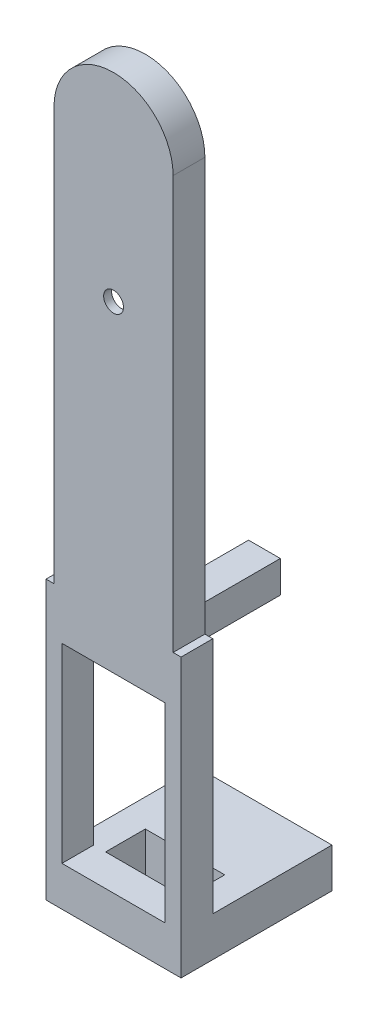
from build123d import *

# Parameters (mm, degrees)
EXTRUDE_1_DEPTH     = 4
CUT_EXTRUDE_1_DEPTH = 3
SKETCH_5_R          = 1.25
CUT_EXTRUDE_2_DEPTH = 12.4
SKETCH_6_W          = 17
SKETCH_6_H          = 35
EXTRUDE_2_DEPTH     = 4
SKETCH_7_W          = 13
SKETCH_7_H          = 24
CUT_EXTRUDE_3_DEPTH = 12.1
SKETCH_8_W          = 4
SKETCH_8_H          = 4
SKETCH_8_R          = 1.175
EXTRUDE_3_DEPTH     = 15
EXTRUDE_4_DEPTH     = 5
SKETCH_10_R         = 1.175
CUT_EXTRUDE_4_DEPTH = 12.7


with BuildPart() as part:
    # 草圖1 → 填料-伸長1 (new body)
    with BuildSketch(Plane.XY):
        with BuildLine():
            Line((7.5, 0), (7.5, 52))
            ThreePointArc((7.5, 52), (0, 59.5), (-7.5, 52))
            Line((-7.5, 52), (-7.5, 0))
            Line((-7.5, 0), (7.5, 0))
        make_face()
    extrude(amount=EXTRUDE_1_DEPTH)

    # 草圖3 → 除料-伸長1 (cut)
    with BuildSketch(Plane.XY):
        with BuildLine():
            ThreePointArc((-2.132795501, 52), (0, 54.132795501), (2.132795501, 52))
            Line((2.132795501, 52), (5, 34.5))
            Line((5, 34.5), (2.114741289, 16.658021353))
            ThreePointArc((2.114741289, 16.658021353), (-0.171540182, 14.864665347), (-2.142213835, 17))
            Line((-2.142213835, 17), (-5, 34.5))
            Line((-5, 34.5), (-2.132795501, 52))
        make_face()
    extrude(amount=CUT_EXTRUDE_1_DEPTH, mode=Mode.SUBTRACT)

    # 草圖5 → 除料-伸長2 (cut)
    with BuildSketch(Plane.XY):
        with Locations((0, 34.5)):
            Circle(SKETCH_5_R)
    extrude(amount=CUT_EXTRUDE_2_DEPTH, mode=Mode.SUBTRACT)

    # 草圖6 → 填料-伸長2 (add)
    with BuildSketch(Plane.XY):
        with Locations((0, -17.5)):
            Rectangle(SKETCH_6_W, SKETCH_6_H)
    extrude(amount=EXTRUDE_2_DEPTH)

    # 草圖7 → 除料-伸長3 (cut)
    with BuildSketch(Plane.XY):
        with Locations((0, -18)):
            Rectangle(SKETCH_7_W, SKETCH_7_H)
    extrude(amount=CUT_EXTRUDE_3_DEPTH, mode=Mode.SUBTRACT)

    # 草圖8 → 填料-伸長3 (add)
    with BuildSketch(Plane.XY):
        with Locations((0, -4)):
            Rectangle(SKETCH_8_W, SKETCH_8_H)
        with Locations((0, -4)):
            Circle(SKETCH_8_R, mode=Mode.SUBTRACT)
    extrude(amount=-EXTRUDE_3_DEPTH)

    # 草圖9 → 填料-伸長4 (add)
    with BuildSketch(Plane(origin=(0, -35, 0), x_dir=(1, 0, 0), z_dir=(0, 1, 0))):
        Polygon((-8.5, 0), (-5, 0), (-5, 5), (5, 5), (5, 0), (8.5, 0), (8.5, 15), (-8.5, 15), align=None)
    extrude(amount=EXTRUDE_4_DEPTH)

    # 草圖10 → 除料-伸長4 (cut)
    with BuildSketch(Plane(origin=(0, 0, -15), x_dir=(-1, 0, 0), z_dir=(0, 0, -1))):
        with Locations((0, -32.5)):
            Circle(SKETCH_10_R)
    extrude(amount=-CUT_EXTRUDE_4_DEPTH, mode=Mode.SUBTRACT)


solid = part.part
